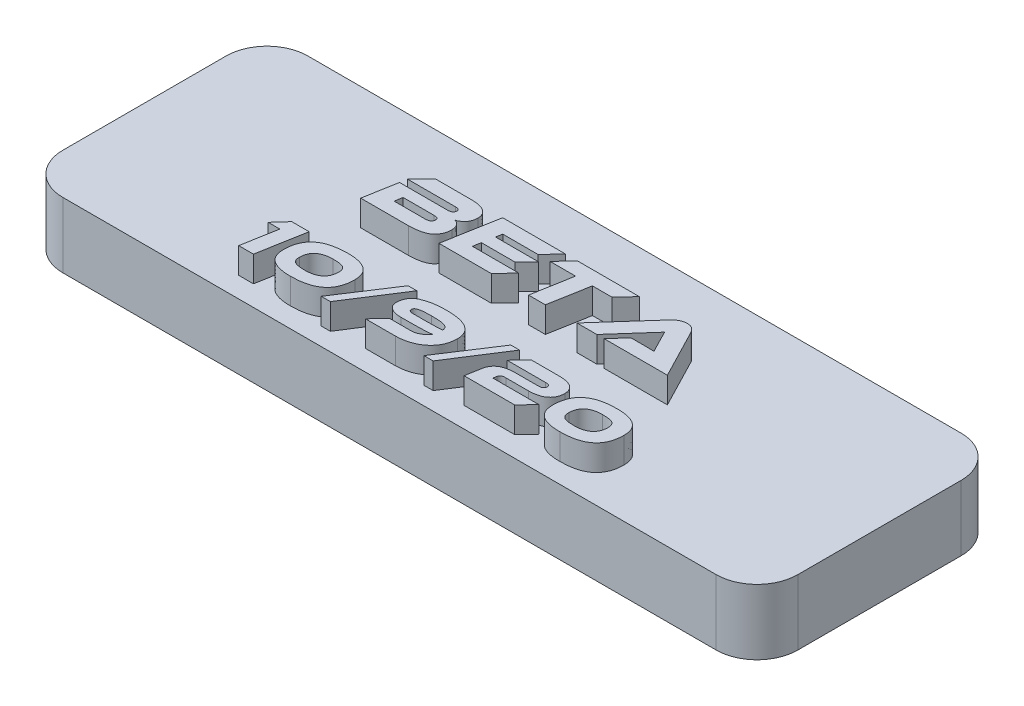
from build123d import *

# Parameters (mm, degrees)
SKETCH1_W           = 57.15
SKETCH1_H           = 19.05
BOSS_EXTRUDE1_DEPTH = 5.08
FILLET1_R           = 3.175
BOSS_EXTRUDE2_DEPTH = 2
SKETCH4_R           = 0.9
CUT_EXTRUDE1_DEPTH  = 4


with BuildPart() as part:
    # Sketch1 → Boss-Extrude1 (new body)
    with BuildSketch(Plane(origin=(0, 0, 0), x_dir=(1, 0, 0), z_dir=(0, 1, 0))):
        Rectangle(SKETCH1_W, SKETCH1_H)
    extrude(amount=BOSS_EXTRUDE1_DEPTH)

    # Fillet1
    fillet1_edges = [part.edges().sort_by_distance(p)[0] for p in [
        (-28.575, 2.54, -9.525),
        (-28.575, 2.54, 9.525),
        (28.575, 2.54, 9.525),
        (28.575, 2.54, -9.525),
    ]]
    fillet(fillet1_edges, radius=FILLET1_R)

    # Sketch3 → Boss-Extrude2 (add)
    with BuildSketch(Plane(origin=(0, 5.08, 0), x_dir=(1, 0, 0), z_dir=(0, 1, 0))):
        with BuildLine():
            Line((12.0752608, 0.006075914), (10.110133747, 3.800574494))
            add(Edge.make_bspline(
                [(10.110133747, 3.800574494), (10.092012803, 3.832806008), (10.056054139, 3.896765269), (9.99118045, 3.985575321), (9.913920963, 4.0630874), (9.829018051, 4.133983071), (9.731212157, 4.192399523), (9.619101008, 4.23493807), (9.49305918, 4.260058315), (9.404328247, 4.264204191), (9.358200531, 4.266359469)],
                knots=[0, 0, 0, 0, 0.000110886, 0.000220038, 0.000328642, 0.000438436, 0.000551159, 0.000668641, 0.000796469, 0.000934872, 0.000934872, 0.000934872, 0.000934872], degree=3))
            add(Edge.make_bspline(
                [(9.358200531, 4.266359469), (9.308388872, 4.264009128), (9.211657751, 4.259444915), (9.071618995, 4.230967468), (8.941340433, 4.187726952), (8.821605558, 4.126959855), (8.711923902, 4.055096369), (8.608722549, 3.977511138), (8.514416335, 3.892229282), (8.457033833, 3.830720556), (8.428505314, 3.800140628)],
                knots=[0, 0, 0, 0, 0.00014941, 0.000290146, 0.000427171, 0.000560039, 0.000691642, 0.000820174, 0.000947034, 0.001072464, 0.001072464, 0.001072464, 0.001072464], degree=3))
            Line((8.428505314, 3.800140628), (5.042507068, 0.006075914))
            Line((5.042507068, 0.006075914), (6.590597512, 0.006075914))
            Line((6.590597512, 0.006075914), (9.067542223, 2.798493231))
            Line((9.067542223, 2.798493231), (9.629909772, 1.696826253))
            add(Edge.make_bspline(
                [(9.629909772, 1.696826253), (9.656583777, 1.644325557), (9.711100024, 1.5370248), (9.780528365, 1.403208105), (9.836611459, 1.297464771), (9.877752573, 1.223921613), (9.914156415, 1.155498073), (9.939454721, 1.112747401), (9.95148686, 1.092414734)],
                knots=[0, 0, 0, 0, 0.000176664, 0.000361065, 0.000452265, 0.000535729, 0.000613867, 0.000684736, 0.000684736, 0.000684736, 0.000684736], degree=3))
            add(Edge.make_bspline(
                [(9.95148686, 1.092414734), (9.896038515, 1.095166522), (9.77787868, 1.101030553), (9.593448145, 1.103502684), (9.398429279, 1.10564963), (9.266176682, 1.105358474), (9.200051787, 1.105212899)],
                knots=[0, 0, 0, 0, 0.000166537, 0.000354888, 0.000553268, 0.00075164, 0.00075164, 0.00075164, 0.00075164], degree=3))
            Line((9.200051787, 1.105212899), (8.145006693, 1.105536066))
            Line((8.145006693, 1.105536066), (7.159283798, 0.006075914))
            Line((7.159283798, 0.006075914), (12.0752608, 0.006075914))
        make_face()
        Polygon((0.896569612, 4.206347541), (-0.152340648, 3.106887389), (1.831742615, 3.106887389), (1.282012539, 0.003655726), (2.589990996, 0.003655726), (3.146039808, 3.106887389), (4.649899097, 3.106887389), (5.698809357, 4.206347541), align=None)
        Polygon((-4.182673258, 1.105536066), (-4.081573474, 1.700326644), (-1.478254033, 1.700326644), (-0.568355976, 2.629107706), (-3.910967588, 2.629107706), (-3.822505277, 3.106887389), (-1.08649237, 3.106887389), (-0.043900846, 4.206347541), (-4.934602903, 4.206347541), (-5.686532547, 0.006075914), (-1.617266236, 0.006075914), (-0.580993449, 1.105536066), align=None)
        with BuildLine():
            add(Edge.make_bspline(
                [(-6.62137524, 2.187185381), (-6.574392147, 2.203247943), (-6.479429873, 2.235713611), (-6.346629309, 2.311746258), (-6.221217039, 2.407162477), (-6.124277095, 2.501677378), (-6.054115517, 2.588230053), (-6.006884659, 2.659861639), (-5.96792723, 2.738536564), (-5.934046167, 2.822101316), (-5.907175532, 2.91174127), (-5.888829435, 3.007382414), (-5.874302744, 3.108635858), (-5.871314591, 3.178462258), (-5.869786618, 3.214167536)],
                knots=[0, 0, 0, 0, 0.00014868, 0.000300512, 0.000456469, 0.000620661, 0.000705179, 0.000790372, 0.000877453, 0.000968101, 0.001060653, 0.001157643, 0.001260037, 0.001367184, 0.001367184, 0.001367184, 0.001367184], degree=3))
            add(Edge.make_bspline(
                [(-5.869786618, 3.214167536), (-5.871317754, 3.253858956), (-5.874292597, 3.330975391), (-5.893774603, 3.443132394), (-5.925851361, 3.547363641), (-5.968980121, 3.644682762), (-6.024442998, 3.734069787), (-6.091490914, 3.816125313), (-6.171525402, 3.889585672), (-6.261864914, 3.956236722), (-6.363340558, 4.014685805), (-6.474468204, 4.065876686), (-6.594977341, 4.109468834), (-6.724857545, 4.145245969), (-6.864222813, 4.172489056), (-7.01330005, 4.191066469), (-7.171650276, 4.203202949), (-7.280303982, 4.205067791), (-7.33609058, 4.206025266)],
                knots=[0, 0, 0, 0, 0.000119065, 0.000231331, 0.000340346, 0.000445509, 0.000549775, 0.000655002, 0.000762375, 0.00087482, 0.000991159, 0.001113043, 0.001241442, 0.001375178, 0.00151681, 0.001667048, 0.001825643, 0.001992996, 0.001992996, 0.001992996, 0.001992996], degree=3))
            Line((-7.33609058, 4.206025266), (-10.134592738, 4.206347541))
            Line((-10.134592738, 4.206347541), (-11.221415418, 3.106887389))
            Line((-11.221415418, 3.106887389), (-7.480723405, 3.106887389))
            add(Edge.make_bspline(
                [(-7.480723405, 3.106887389), (-7.460194509, 3.106630193), (-7.420198205, 3.106129099), (-7.362335635, 3.096227406), (-7.307789509, 3.082436236), (-7.258910264, 3.060323439), (-7.215055925, 3.033212332), (-7.184027367, 2.993605071), (-7.163990004, 2.94620226), (-7.160547969, 2.911487381), (-7.158744589, 2.893299275)],
                knots=[0, 0, 0, 0, 6.1492e-05, 0.000119805, 0.000175688, 0.000229709, 0.000280417, 0.00032853, 0.000378106, 0.000432665, 0.000432665, 0.000432665, 0.000432665], degree=3))
            add(Edge.make_bspline(
                [(-7.158744589, 2.893299275), (-7.160845469, 2.86535707), (-7.164816521, 2.812541115), (-7.189765276, 2.739999455), (-7.230089964, 2.680494349), (-7.286111613, 2.637439539), (-7.350700379, 2.607321442), (-7.420805557, 2.585171427), (-7.496494738, 2.572149557), (-7.54873238, 2.571128072), (-7.575599082, 2.570602705)],
                knots=[0, 0, 0, 0, 8.3794e-05, 0.000158386, 0.00022736, 0.000296317, 0.000367457, 0.000440314, 0.00051636, 0.000596888, 0.000596888, 0.000596888, 0.000596888], degree=3))
            Line((-7.575599082, 2.570602705), (-11.316196465, 2.570602705))
            Line((-11.316196465, 2.570602705), (-11.771145494, 0.006075914))
            Line((-11.771145494, 0.006075914), (-8.055728427, 0.006075914))
            add(Edge.make_bspline(
                [(-8.055728427, 0.006075914), (-8.007813998, 0.007160551), (-7.913832928, 0.009287995), (-7.77565589, 0.016528554), (-7.643406781, 0.027708855), (-7.516806903, 0.041002161), (-7.39646095, 0.05863916), (-7.281968355, 0.078249741), (-7.173837221, 0.102363743), (-7.071639778, 0.128677059), (-6.975293754, 0.15753505), (-6.885555278, 0.190923237), (-6.801211148, 0.225988083), (-6.7235526, 0.265520731), (-6.651572249, 0.307621373), (-6.585885427, 0.353192579), (-6.52608555, 0.401906842), (-6.454971452, 0.469570838), (-6.377484359, 0.559682823), (-6.296411863, 0.672139808), (-6.229413032, 0.789030817), (-6.174871285, 0.909130077), (-6.134412663, 1.033306932), (-6.107787145, 1.161416316), (-6.094726804, 1.293563918), (-6.096509599, 1.382790133), (-6.097411111, 1.427909469)],
                knots=[0, 0, 0, 0, 0.000143776, 0.000282006, 0.000415012, 0.000541908, 0.00066382, 0.000779846, 0.000890304, 0.000996066, 0.00109641, 0.001191851, 0.001283198, 0.001370278, 0.001453058, 0.001533192, 0.001609861, 0.001684223, 0.001827407, 0.001965662, 0.002099572, 0.002230912, 0.002360712, 0.002490516, 0.002622775, 0.002758069, 0.002758069, 0.002758069, 0.002758069], degree=3))
            add(Edge.make_bspline(
                [(-6.097411111, 1.427909469), (-6.099692649, 1.477115185), (-6.104083433, 1.571810809), (-6.132511037, 1.706327142), (-6.178178559, 1.82651134), (-6.241887111, 1.930896451), (-6.320395963, 2.019144873), (-6.410176192, 2.092252982), (-6.510857336, 2.150664811), (-6.584718259, 2.174555082), (-6.62137524, 2.187185381)],
                knots=[0, 0, 0, 0, 0.000147587, 0.000284029, 0.000410503, 0.000531538, 0.000648753, 0.000763114, 0.000877748, 0.000995447, 0.000995447, 0.000995447, 0.000995447], degree=3))
        make_face()
        with BuildLine():
            add(Edge.make_bspline(
                [(-7.758747812, 1.700326644), (-7.72964301, 1.6994496), (-7.675229926, 1.697809917), (-7.599287501, 1.685948139), (-7.534808332, 1.667640036), (-7.481478653, 1.640873892), (-7.440061143, 1.605602768), (-7.410354167, 1.562218177), (-7.394615813, 1.510308523), (-7.393406209, 1.473719839), (-7.392768164, 1.454419952)],
                knots=[0, 0, 0, 0, 8.7282e-05, 0.000163179, 0.000229987, 0.000287637, 0.000340784, 0.000391493, 0.000443246, 0.000501019, 0.000501019, 0.000501019, 0.000501019], degree=3))
            add(Edge.make_bspline(
                [(-7.392768164, 1.454419952), (-7.393315993, 1.427741553), (-7.394362634, 1.376771745), (-7.416286578, 1.305287655), (-7.452431754, 1.243763895), (-7.505459566, 1.194029008), (-7.572544294, 1.153999021), (-7.655874146, 1.128239985), (-7.752723085, 1.109272203), (-7.822612126, 1.106625198), (-7.859901159, 1.105212899)],
                knots=[0, 0, 0, 0, 7.972e-05, 0.000152308, 0.000221603, 0.000291427, 0.00036809, 0.000453948, 0.00055166, 0.000663426, 0.000663426, 0.000663426, 0.000663426], degree=3))
            Line((-7.859901159, 1.105212899), (-10.267286205, 1.105536066))
            Line((-10.267286205, 1.105536066), (-10.166186421, 1.700326644))
            Line((-10.166186421, 1.700326644), (-7.758747812, 1.700326644))
        make_face(mode=Mode.SUBTRACT)
        with BuildLine():
            add(Edge.make_bspline(
                [(12.374340669, -4.205753245), (12.317239313, -4.20639815), (12.204907242, -4.207666832), (12.039195816, -4.213805403), (11.879185029, -4.225246011), (11.724671425, -4.240095428), (11.575776648, -4.260037206), (11.432559303, -4.284920981), (11.294647723, -4.313802188), (11.162098696, -4.346120038), (11.035284787, -4.383749272), (10.91434756, -4.426552533), (10.798324929, -4.472224962), (10.688470655, -4.524117338), (10.583401962, -4.578873484), (10.484385667, -4.638857599), (10.390911032, -4.703243715), (10.303097022, -4.771965987), (10.220238789, -4.844826576), (10.143245148, -4.922821718), (10.071680184, -5.005043307), (10.004270552, -5.090962924), (9.944161792, -5.18251662), (9.887569921, -5.277290921), (9.838403852, -5.377585075), (9.792275881, -5.480915677), (9.753402255, -5.589719203), (9.719021538, -5.702636581), (9.689210536, -5.819692193), (9.666355584, -5.941608197), (9.647756444, -6.06752364), (9.635447597, -6.198094357), (9.626896949, -6.332815699), (9.626182493, -6.424102975), (9.625819287, -6.470510423)],
                knots=[0, 0, 0, 0, 0.000171312, 0.000337012, 0.00049738, 0.000652505, 0.000802621, 0.000947932, 0.001088493, 0.001225264, 0.001357119, 0.001485126, 0.001610044, 0.001730996, 0.001849428, 0.001965345, 0.002078058, 0.002189744, 0.002299681, 0.002408844, 0.002518253, 0.002626572, 0.002736165, 0.002846598, 0.002957491, 0.003071033, 0.00318591, 0.003303822, 0.003425073, 0.003548063, 0.003675777, 0.003806785, 0.003941403, 0.004080604, 0.004080604, 0.004080604, 0.004080604], degree=3))
            add(Edge.make_bspline(
                [(9.625819287, -6.470510423), (9.627176941, -6.532725476), (9.629810681, -6.653417738), (9.655197803, -6.827938058), (9.695721021, -6.990047106), (9.7525154, -7.14024227), (9.82646111, -7.277956037), (9.917021702, -7.403136721), (10.023352013, -7.515956622), (10.146409566, -7.616000774), (10.285895861, -7.702745849), (10.440515685, -7.779438213), (10.611628328, -7.842507446), (10.798186883, -7.895609169), (11.001002293, -7.935791135), (11.219583172, -7.964127031), (11.454092052, -7.98091947), (11.615638791, -7.982880129), (11.699121896, -7.983893345)],
                knots=[0, 0, 0, 0, 0.000186545, 0.000361882, 0.000527754, 0.000687003, 0.000842323, 0.000995285, 0.001149196, 0.001306104, 0.001469661, 0.00164101, 0.001823006, 0.002015943, 0.002222385, 0.002442644, 0.002676813, 0.00292724, 0.00292724, 0.00292724, 0.00292724], degree=3))
            add(Edge.make_bspline(
                [(11.699121896, -7.983893345), (11.75591946, -7.983380019), (11.867417529, -7.98237232), (12.032008362, -7.975990544), (12.191023017, -7.965003258), (12.344878401, -7.948680913), (12.493330341, -7.929266178), (12.635969307, -7.904105738), (12.773236057, -7.875596387), (12.904737671, -7.841995411), (13.031086924, -7.804464931), (13.151623906, -7.761989808), (13.267162184, -7.715814846), (13.37695752, -7.664606669), (13.48093553, -7.608490903), (13.579854168, -7.548339608), (13.673226984, -7.483895632), (13.760936312, -7.414499954), (13.843341161, -7.341424669), (13.919342052, -7.262809113), (13.991930735, -7.18190029), (14.057459891, -7.094705032), (14.118138242, -7.003516426), (14.174549308, -6.908219643), (14.224711509, -6.808134503), (14.269649232, -6.703993625), (14.308740694, -6.595424725), (14.343410979, -6.482622195), (14.371732995, -6.364960314), (14.395969103, -6.243348255), (14.414375056, -6.117331748), (14.426750069, -5.986773695), (14.43522599, -5.851777937), (14.435958151, -5.760225753), (14.436329275, -5.713818961)],
                knots=[0, 0, 0, 0, 0.000170392, 0.000334494, 0.000494064, 0.000648473, 0.00079859, 0.000943113, 0.001082891, 0.001219081, 0.001350169, 0.001478176, 0.001602352, 0.001723304, 0.001841405, 0.001956639, 0.002070464, 0.002181522, 0.00229199, 0.002400592, 0.0025094, 0.002617866, 0.002727459, 0.002837893, 0.002949859, 0.003063082, 0.00317796, 0.003295871, 0.003416929, 0.003540857, 0.00366778, 0.003798788, 0.003934205, 0.004073405, 0.004073405, 0.004073405, 0.004073405], degree=3))
            add(Edge.make_bspline(
                [(14.436329275, -5.713818961), (14.43498762, -5.651864372), (14.432379489, -5.53142685), (14.406666925, -5.357329546), (14.367479439, -5.194951682), (14.310453972, -5.045253766), (14.237085855, -4.907894424), (14.147830754, -4.782830639), (14.041725948, -4.670804764), (13.920105144, -4.570938519), (13.781557034, -4.484275151), (13.627367339, -4.409545186), (13.457489134, -4.345204255), (13.271561733, -4.293863202), (13.069630563, -4.25419887), (12.852168928, -4.225768444), (12.618455287, -4.209016704), (12.457441416, -4.207051109), (12.374340669, -4.205753245)],
                knots=[0, 0, 0, 0, 0.000185746, 0.000361083, 0.00052676, 0.000686009, 0.000840246, 0.000992741, 0.001145521, 0.00130181, 0.001463587, 0.001634583, 0.001815083, 0.002007802, 0.002212518, 0.002431984, 0.002665356, 0.002914983, 0.002914983, 0.002914983, 0.002914983], degree=3))
        make_face()
        with BuildLine():
            add(Edge.make_bspline(
                [(11.86568238, -7.021348599), (11.8194893, -7.021854174), (11.730334765, -7.022829956), (11.60141977, -7.017591194), (11.482074307, -7.009340097), (11.372313208, -6.995853431), (11.272049166, -6.977791428), (11.181505833, -6.954558851), (11.100166608, -6.92776808), (11.027958792, -6.89577873), (10.96396743, -6.85746675), (10.909940859, -6.809228041), (10.863371147, -6.753532905), (10.826820836, -6.688452997), (10.797685771, -6.615916979), (10.778224967, -6.534816355), (10.765912812, -6.445830998), (10.765217218, -6.383634321), (10.764855906, -6.351327518)],
                knots=[0, 0, 0, 0, 0.000138565, 0.000267436, 0.000386943, 0.000497368, 0.000599032, 0.000692348, 0.000777591, 0.00085564, 0.000928899, 0.001000308, 0.001071897, 0.001145712, 0.001223247, 0.001305698, 0.001395292, 0.001492131, 0.001492131, 0.001492131, 0.001492131], degree=3))
            add(Edge.make_bspline(
                [(10.764855906, -6.351327518), (10.766392759, -6.304070169), (10.769382846, -6.212126705), (10.788044786, -6.079013736), (10.817300229, -5.954439253), (10.859118048, -5.839274516), (10.911175676, -5.731825667), (10.976385898, -5.634468641), (11.052201768, -5.545120744), (11.140147315, -5.466071948), (11.238120391, -5.395226287), (11.346722869, -5.334487382), (11.465103405, -5.283435533), (11.592697011, -5.240941797), (11.730029982, -5.208296683), (11.876899843, -5.185693562), (12.033434061, -5.170762309), (12.141155378, -5.169135367), (12.196650531, -5.16829721)],
                knots=[0, 0, 0, 0, 0.000141763, 0.000275812, 0.0004025, 0.000524963, 0.000642655, 0.000759791, 0.000875529, 0.00099331, 0.001113634, 0.001237554, 0.001365798, 0.001499859, 0.001640517, 0.001788722, 0.001945363, 0.002111808, 0.002111808, 0.002111808, 0.002111808], degree=3))
            add(Edge.make_bspline(
                [(12.196650531, -5.16829721), (12.242779181, -5.168009724), (12.3318575, -5.167454564), (12.461007813, -5.171313587), (12.580618945, -5.17974049), (12.690556031, -5.193477036), (12.790849239, -5.210588071), (12.881560995, -5.232796313), (12.962755297, -5.25982086), (13.035040085, -5.291687778), (13.098665678, -5.330152418), (13.153061044, -5.377160874), (13.19864834, -5.432670471), (13.235572883, -5.496790682), (13.264422198, -5.569240936), (13.283849223, -5.650050065), (13.29628475, -5.738759012), (13.296947129, -5.80069376), (13.297292657, -5.833001866)],
                knots=[0, 0, 0, 0, 0.00013838, 0.000267224, 0.000387529, 0.000497953, 0.000599476, 0.000692596, 0.00077784, 0.000855889, 0.000929147, 0.001000031, 0.001070493, 0.001143616, 0.001221151, 0.001303602, 0.001392403, 0.001489242, 0.001489242, 0.001489242, 0.001489242], degree=3))
            add(Edge.make_bspline(
                [(13.297292657, -5.833001866), (13.295755137, -5.880258006), (13.292763753, -5.972199119), (13.274074918, -6.105585977), (13.244713969, -6.230260661), (13.204011304, -6.346409008), (13.151009147, -6.453739693), (13.085591885, -6.551573704), (13.009947875, -6.64153852), (12.922305875, -6.721564153), (12.823890928, -6.791879743), (12.716346043, -6.854243117), (12.597796705, -6.904835069), (12.470156572, -6.947243215), (12.332961399, -6.980841995), (12.185859835, -7.004512108), (12.028969086, -7.019068958), (11.920989456, -7.020761541), (11.86568238, -7.021348599)],
                knots=[0, 0, 0, 0, 0.000141763, 0.000275812, 0.000403278, 0.000525472, 0.000644235, 0.000761371, 0.000877718, 0.000996039, 0.001116363, 0.001239983, 0.001368227, 0.001502288, 0.001643134, 0.001791467, 0.001948904, 0.002115349, 0.002115349, 0.002115349, 0.002115349], degree=3))
        make_face(mode=Mode.SUBTRACT)
        with BuildLine():
            Line((4.843044384, -5.218973535), (7.834176278, -5.218973535))
            add(Edge.make_bspline(
                [(7.834176278, -5.218973535), (7.861877192, -5.218922741), (7.913723567, -5.218827674), (7.98645257, -5.225918073), (8.047976611, -5.242216387), (8.099807148, -5.26353583), (8.139900537, -5.294908436), (8.168214537, -5.334273792), (8.185766514, -5.381008794), (8.186991214, -5.4147712), (8.18762558, -5.432259348)],
                knots=[0, 0, 0, 0, 8.3099e-05, 0.000155531, 0.000218392, 0.000273538, 0.000322508, 0.000368908, 0.000417497, 0.000469711, 0.000469711, 0.000469711, 0.000469711], degree=3))
            add(Edge.make_bspline(
                [(8.18762558, -5.432259348), (8.186985786, -5.458018948), (8.185776182, -5.506720508), (8.165213796, -5.573936821), (8.13192742, -5.630194031), (8.082713797, -5.673414306), (8.019182698, -5.704561408), (7.941448531, -5.726311626), (7.848323372, -5.738498194), (7.781321727, -5.73961472), (7.745289028, -5.740215175)],
                knots=[0, 0, 0, 0, 7.6993e-05, 0.000145564, 0.000208395, 0.000270703, 0.000339032, 0.00041902, 0.000511893, 0.000619952, 0.000619952, 0.000619952, 0.000619952], degree=3))
            Line((7.745289028, -5.740215175), (5.987525534, -5.739416071))
            add(Edge.make_bspline(
                [(5.987525534, -5.739416071), (5.931923378, -5.740560639), (5.823670216, -5.742789025), (5.665674889, -5.753609346), (5.51695553, -5.772857955), (5.377332662, -5.798779792), (5.247069464, -5.833149331), (5.125990611, -5.875619954), (5.013723231, -5.92500466), (4.910521364, -5.98174212), (4.817052167, -6.047028209), (4.732526674, -6.120143527), (4.657126065, -6.201107035), (4.591125043, -6.289606037), (4.534743469, -6.385733808), (4.487647714, -6.489539314), (4.448700351, -6.600822081), (4.431378675, -6.678800473), (4.422565634, -6.718474855)],
                knots=[0, 0, 0, 0, 0.000166829, 0.000324804, 0.000474816, 0.000616477, 0.000750546, 0.000878553, 0.001001026, 0.001118108, 0.001231277, 0.001342418, 0.001452782, 0.001562526, 0.00167296, 0.001786425, 0.001904052, 0.002025887, 0.002025887, 0.002025887, 0.002025887], degree=3))
            Line((4.422565634, -6.718474855), (4.207221523, -7.932183575))
            Line((4.207221523, -7.932183575), (8.143794367, -7.932183575))
            Line((8.143794367, -7.932183575), (9.050533056, -6.970155942))
            Line((9.050533056, -6.970155942), (5.478867245, -6.970155942))
            Line((5.478867245, -6.970155942), (5.528627295, -6.707239748))
            add(Edge.make_bspline(
                [(5.528627295, -6.707239748), (5.532404819, -6.686112106), (5.539727576, -6.645156023), (5.568438929, -6.590591717), (5.606799622, -6.543848716), (5.658138953, -6.508043577), (5.71921442, -6.47963759), (5.79153204, -6.461031101), (5.874595461, -6.450993538), (5.933518971, -6.450679637), (5.964744426, -6.450513291)],
                knots=[0, 0, 0, 0, 6.4036e-05, 0.000124134, 0.000182613, 0.000243892, 0.000310094, 0.000383827, 0.000466868, 0.000560486, 0.000560486, 0.000560486, 0.000560486], degree=3))
            Line((5.964744426, -6.450513291), (7.723598389, -6.449714187))
            add(Edge.make_bspline(
                [(7.723598389, -6.449714187), (7.789279414, -6.448593152), (7.916613855, -6.446419826), (8.100511704, -6.426694059), (8.271928314, -6.400940141), (8.4297752, -6.361961645), (8.575529194, -6.315052912), (8.706870449, -6.255202462), (8.826343564, -6.187512089), (8.931056004, -6.107690588), (9.023639196, -6.020066732), (9.104095557, -5.925525662), (9.171874442, -5.823724541), (9.227627244, -5.715194429), (9.269763213, -5.599220599), (9.300458649, -5.476792913), (9.318113994, -5.347458364), (9.320066948, -5.259004345), (9.321063001, -5.21389067)],
                knots=[0, 0, 0, 0, 0.00019697, 0.000381861, 0.000554393, 0.000716581, 0.000869107, 0.001013024, 0.00114885, 0.001280192, 0.001406932, 0.001530654, 0.001651783, 0.001773055, 0.001895792, 0.002021116, 0.002151095, 0.002286391, 0.002286391, 0.002286391, 0.002286391], degree=3))
            add(Edge.make_bspline(
                [(9.321063001, -5.21389067), (9.320610546, -5.1780961), (9.319724802, -5.108023129), (9.303514954, -5.005989197), (9.279522882, -4.909275966), (9.242988179, -4.818686266), (9.195353826, -4.734234215), (9.137274784, -4.655338408), (9.068907157, -4.582231577), (8.989612717, -4.515185386), (8.8987898, -4.455053695), (8.79521118, -4.402688892), (8.678978059, -4.359688685), (8.55079058, -4.322394884), (8.409987571, -4.294289614), (8.256640525, -4.27367202), (8.090773995, -4.26108405), (7.975944379, -4.258543735), (7.916464475, -4.257227893)],
                knots=[0, 0, 0, 0, 0.000107259, 0.000209975, 0.000309113, 0.00040566, 0.000501999, 0.00059927, 0.000698874, 0.0008016, 0.000910084, 0.001024914, 0.001148961, 0.001281358, 0.001425053, 0.00157924, 0.00174531, 0.001923772, 0.001923772, 0.001923772, 0.001923772], degree=3))
            Line((7.916464475, -4.257227893), (5.749783073, -4.256945902))
            Line((5.749783073, -4.256945902), (4.843044384, -5.218973535))
        make_face()
        Polygon((3.957233943, -4.05005839), (1.292306821, -8.139071868), (2.005534204, -8.139071868), (4.631759065, -4.05005839), align=None)
        with BuildLine():
            Line((-2.557665164, -6.970155942), (-3.452921125, -7.932183575))
            Line((-3.452921125, -7.932183575), (-1.134743484, -7.932183575))
            add(Edge.make_bspline(
                [(-1.134743484, -7.932183575), (-1.044897228, -7.929777147), (-0.868327525, -7.92504793), (-0.609316661, -7.89377972), (-0.36127733, -7.845456505), (-0.124789016, -7.778119368), (0.100483785, -7.693257531), (0.314160255, -7.589683886), (0.516243704, -7.467776465), (0.674424764, -7.351552012), (0.793660056, -7.251102183), (0.877009845, -7.171271707), (0.955534864, -7.089073015), (1.028750052, -7.003301544), (1.095489507, -6.913691428), (1.157823493, -6.821436558), (1.213384965, -6.725101624), (1.265039621, -6.626227548), (1.309699037, -6.523415525), (1.348869977, -6.417304195), (1.383510073, -6.308297587), (1.411113964, -6.195383605), (1.434865164, -6.079711014), (1.450910869, -5.960192069), (1.463548774, -5.837767761), (1.466896702, -5.75491021), (1.468589348, -5.713019076)],
                knots=[0, 0, 0, 0, 0.000269512, 0.000529657, 0.000781592, 0.001026938, 0.001266417, 0.001502887, 0.001738287, 0.001973466, 0.00209094, 0.002205793, 0.002319514, 0.002431869, 0.002543853, 0.002654555, 0.002765679, 0.002877297, 0.002989052, 0.003101677, 0.003216532, 0.003331962, 0.003450243, 0.003570604, 0.003693573, 0.003819318, 0.003819318, 0.003819318, 0.003819318], degree=3))
            add(Edge.make_bspline(
                [(1.468589348, -5.713019076), (1.466464228, -5.652117472), (1.462330437, -5.533651456), (1.433941811, -5.361744864), (1.387653029, -5.20161806), (1.323431746, -5.05300733), (1.240814082, -4.916595218), (1.141285742, -4.79126316), (1.021584981, -4.67984859), (0.886130694, -4.578328397), (0.73142821, -4.490460709), (0.55969407, -4.413762538), (0.370014239, -4.349318484), (0.162950263, -4.296844754), (-0.061910703, -4.256528236), (-0.304420412, -4.227593809), (-0.564681799, -4.208531898), (-0.744124273, -4.206884801), (-0.836679988, -4.206035236)],
                knots=[0, 0, 0, 0, 0.00018267, 0.00035533, 0.000521131, 0.000681619, 0.000839513, 0.000998287, 0.001160113, 0.00132873, 0.001505033, 0.001692644, 0.001892226, 0.002105242, 0.002332894, 0.00257706, 0.002837673, 0.00311529, 0.00311529, 0.00311529, 0.00311529], degree=3))
            add(Edge.make_bspline(
                [(-0.836679988, -4.206035236), (-0.919878842, -4.205592276), (-1.083417671, -4.204721577), (-1.324656293, -4.215578286), (-1.557477121, -4.234927868), (-1.781903272, -4.265660573), (-1.998050571, -4.305110003), (-2.205472113, -4.355643498), (-2.404392321, -4.415783415), (-2.563836838, -4.473503284), (-2.685697056, -4.525130752), (-2.770163401, -4.569635858), (-2.850171078, -4.616422557), (-2.923378106, -4.668834502), (-2.992257643, -4.723868288), (-3.054465933, -4.784450305), (-3.112433697, -4.847987079), (-3.163798753, -4.916899938), (-3.210180339, -4.989145242), (-3.250361198, -5.066161285), (-3.285603592, -5.146801308), (-3.315168699, -5.2318633), (-3.339172718, -5.32088445), (-3.357438248, -5.41389817), (-3.37046186, -5.510872203), (-3.3743422, -5.57700115), (-3.376315707, -5.610633762)],
                knots=[0, 0, 0, 0, 0.000249565, 0.000490555, 0.000724179, 0.0009502, 0.001169841, 0.001383052, 0.001590297, 0.00179299, 0.001891509, 0.001987031, 0.002079216, 0.002169319, 0.002256891, 0.002343445, 0.002429536, 0.002514644, 0.002600961, 0.002686833, 0.002774954, 0.002864759, 0.002956732, 0.003051325, 0.003148954, 0.003249996, 0.003249996, 0.003249996, 0.003249996], degree=3))
            add(Edge.make_bspline(
                [(-3.376315707, -5.610633762), (-3.374880852, -5.643753438), (-3.372075356, -5.708510641), (-3.356193962, -5.802650158), (-3.329206547, -5.890402518), (-3.294403331, -5.972873051), (-3.248285948, -6.048807605), (-3.191721599, -6.117637999), (-3.126110505, -6.18094304), (-3.050646005, -6.237416652), (-2.966679944, -6.287658407), (-2.874653991, -6.330947125), (-2.775047598, -6.367615523), (-2.667608804, -6.398128227), (-2.552233717, -6.420818141), (-2.429374898, -6.437537883), (-2.29904804, -6.448004733), (-2.209569457, -6.449663014), (-2.163689644, -6.450513291)],
                knots=[0, 0, 0, 0, 9.9392e-05, 0.000194336, 0.000285432, 0.000374287, 0.00046222, 0.000550917, 0.000640864, 0.000735091, 0.000833037, 0.000933937, 0.001039728, 0.001151139, 0.001268635, 0.001392165, 0.00152296, 0.001660599, 0.001660599, 0.001660599, 0.001660599], degree=3))
            add(Edge.make_bspline(
                [(-2.163689644, -6.450513291), (-2.110097138, -6.450588766), (-2.005311096, -6.450736339), (-1.851734394, -6.449683936), (-1.704822078, -6.448934551), (-1.564841867, -6.448155746), (-1.431528578, -6.447263447), (-1.305140899, -6.446777451), (-1.185429975, -6.444902162), (-1.07237807, -6.443402764), (-0.966262797, -6.441665317), (-0.867061298, -6.440519694), (-0.774568218, -6.437415789), (-0.6889522, -6.436504009), (-0.610042771, -6.433778787), (-0.538056481, -6.43134803), (-0.472699753, -6.429349577), (-0.395959363, -6.424605461), (-0.308700962, -6.420771207), (-0.211432537, -6.413793257), (-0.122833184, -6.408049685), (-0.042959266, -6.400065169), (0.028426402, -6.394706302), (0.090717672, -6.386176476), (0.1443788, -6.378534723), (0.177056765, -6.372485855), (0.191972464, -6.369724879)],
                knots=[0, 0, 0, 0, 0.000160777, 0.000314357, 0.000460738, 0.00060152, 0.000734304, 0.000860688, 0.000980681, 0.001093477, 0.001199873, 0.001299072, 0.00139109, 0.001477493, 0.001555918, 0.001627948, 0.001693582, 0.001752061, 0.001858593, 0.001955591, 0.002044608, 0.00212492, 0.002196397, 0.002259299, 0.002313485, 0.002358987, 0.002358987, 0.002358987, 0.002358987], degree=3))
            add(Edge.make_bspline(
                [(0.191972464, -6.369724879), (0.162251408, -6.410755391), (0.102406135, -6.493372984), (-0.005287966, -6.604032197), (-0.12521206, -6.70577684), (-0.235755023, -6.780745718), (-0.330711064, -6.833676621), (-0.405510818, -6.868964979), (-0.482751272, -6.899761591), (-0.563643191, -6.923136897), (-0.646719372, -6.943784293), (-0.733436784, -6.957621584), (-0.822853723, -6.967749518), (-0.883577836, -6.969535864), (-0.914268859, -6.970438714)],
                knots=[0, 0, 0, 0, 0.000151822, 0.000305704, 0.000461788, 0.000623076, 0.000705429, 0.000787724, 0.000871054, 0.000954565, 0.001040123, 0.001127702, 0.001217802, 0.001309875, 0.001309875, 0.001309875, 0.001309875], degree=3))
            Line((-0.914268859, -6.970438714), (-2.557665164, -6.970155942))
        make_face()
        with BuildLine():
            add(Edge.make_bspline(
                [(-1.947490967, -5.739416071), (-1.975875986, -5.739333167), (-2.0290647, -5.739177819), (-2.102815029, -5.728388524), (-2.165702433, -5.712937853), (-2.217625578, -5.691097621), (-2.258744812, -5.66209877), (-2.286959552, -5.625127048), (-2.305091841, -5.582069955), (-2.306262538, -5.550830586), (-2.306869106, -5.534644662)],
                knots=[0, 0, 0, 0, 8.5051e-05, 0.000159372, 0.000223007, 0.000278884, 0.00032752, 0.000371998, 0.000416856, 0.000465088, 0.000465088, 0.000465088, 0.000465088], degree=3))
            add(Edge.make_bspline(
                [(-2.306869106, -5.534644662), (-2.308071392, -5.520492659), (-2.310425318, -5.492784798), (-2.302478644, -5.451904192), (-2.287198755, -5.413284736), (-2.262284421, -5.377865243), (-2.229997418, -5.344746874), (-2.188732514, -5.315137149), (-2.140104097, -5.287204256), (-2.081620395, -5.262102266), (-2.011125451, -5.239181686), (-1.924986563, -5.220969825), (-1.823044429, -5.204302076), (-1.704772838, -5.19102051), (-1.570305014, -5.180808804), (-1.419313849, -5.174134861), (-1.252121235, -5.169033665), (-1.135308398, -5.168550026), (-1.074245912, -5.16829721)],
                knots=[0, 0, 0, 0, 4.2424e-05, 8.3061e-05, 0.000123611, 0.000166209, 0.000212026, 0.00026178, 0.000318034, 0.000380003, 0.000452348, 0.000540062, 0.000643816, 0.000762183, 0.000896965, 0.001048315, 0.00121556, 0.00139874, 0.00139874, 0.00139874, 0.00139874], degree=3))
            add(Edge.make_bspline(
                [(-1.074245912, -5.16829721), (-1.021719383, -5.167787601), (-0.919593467, -5.166796781), (-0.77104867, -5.169363834), (-0.631768573, -5.174373781), (-0.501942193, -5.184530804), (-0.381245923, -5.195834798), (-0.269863294, -5.211544935), (-0.168123775, -5.232098586), (-0.074910827, -5.253456427), (0.008709933, -5.280784321), (0.082199887, -5.316195779), (0.144842199, -5.359607715), (0.198410433, -5.409671023), (0.24015145, -5.468468051), (0.273006103, -5.534032814), (0.293452939, -5.607713922), (0.299334903, -5.659314386), (0.30235663, -5.685822977)],
                knots=[0, 0, 0, 0, 0.000157579, 0.000306377, 0.00044567, 0.000575606, 0.000696984, 0.000809313, 0.000912848, 0.001008299, 0.001096072, 0.001176204, 0.001252088, 0.00132394, 0.001394981, 0.001467241, 0.001542944, 0.00162292, 0.00162292, 0.00162292, 0.00162292], degree=3))
            add(Edge.make_bspline(
                [(0.30235663, -5.685822977), (0.284765926, -5.688016622), (0.247218461, -5.692698971), (0.187461376, -5.698817251), (0.120886582, -5.705774202), (0.047459513, -5.709867374), (-0.032516243, -5.714809123), (-0.119152794, -5.719762177), (-0.212483555, -5.723691176), (-0.31568316, -5.726773296), (-0.434853019, -5.730355113), (-0.576450031, -5.73231403), (-0.743357416, -5.734779827), (-0.93532691, -5.737306699), (-1.152632385, -5.738848781), (-1.395266673, -5.739352636), (-1.663227301, -5.740463735), (-1.850134484, -5.740300435), (-1.947490967, -5.739416071)],
                knots=[0, 0, 0, 0, 5.3179e-05, 0.000113511, 0.000180209, 0.000253954, 0.000334087, 0.000420608, 0.00051428, 0.000614317, 0.000730344, 0.000871944, 0.001039137, 0.001231125, 0.0014479, 0.001691066, 0.001959029, 0.002251787, 0.002251787, 0.002251787, 0.002251787], degree=3))
        make_face(mode=Mode.SUBTRACT)
        Polygon((-4.02882055, -4.05005839), (-6.693747672, -8.139071868), (-5.980520288, -8.139071868), (-3.354295428, -4.05005839), align=None)
        with BuildLine():
            add(Edge.make_bspline(
                [(-8.563456046, -4.205753245), (-8.620557402, -4.20639815), (-8.732889473, -4.207666832), (-8.898600899, -4.213805403), (-9.058611686, -4.225246011), (-9.21312529, -4.240095428), (-9.362020067, -4.260037206), (-9.505237412, -4.284920981), (-9.643148992, -4.313802188), (-9.775698019, -4.346120038), (-9.902511928, -4.383749272), (-10.023449155, -4.426552533), (-10.139471786, -4.472224962), (-10.24932606, -4.524117338), (-10.354394753, -4.578873484), (-10.453411048, -4.638857599), (-10.546885683, -4.703243715), (-10.634699693, -4.771965987), (-10.717557926, -4.844826576), (-10.794551567, -4.922821718), (-10.866116531, -5.005043307), (-10.933526163, -5.090962924), (-10.993634923, -5.18251662), (-11.050226794, -5.277290921), (-11.099392862, -5.377585075), (-11.145520834, -5.480915677), (-11.184394459, -5.589719203), (-11.218775177, -5.702636581), (-11.248586179, -5.819692193), (-11.271441131, -5.941608197), (-11.29004027, -6.06752364), (-11.302349118, -6.198094357), (-11.310899766, -6.332815699), (-11.311614222, -6.424102975), (-11.311977428, -6.470510423)],
                knots=[0, 0, 0, 0, 0.000171312, 0.000337012, 0.00049738, 0.000652505, 0.000802621, 0.000947932, 0.001088493, 0.001225264, 0.001357119, 0.001485126, 0.001610044, 0.001730996, 0.001849428, 0.001965345, 0.002078058, 0.002189744, 0.002299681, 0.002408844, 0.002518253, 0.002626572, 0.002736165, 0.002846598, 0.002957491, 0.003071033, 0.00318591, 0.003303822, 0.003425073, 0.003548063, 0.003675777, 0.003806785, 0.003941403, 0.004080604, 0.004080604, 0.004080604, 0.004080604], degree=3))
            add(Edge.make_bspline(
                [(-11.311977428, -6.470510423), (-11.310619774, -6.532725476), (-11.307986034, -6.653417738), (-11.282598912, -6.827938058), (-11.242075694, -6.990047106), (-11.185281315, -7.14024227), (-11.111335605, -7.277956037), (-11.020775013, -7.403136721), (-10.914444702, -7.515956622), (-10.791387149, -7.616000774), (-10.651900854, -7.702745849), (-10.49728103, -7.779438213), (-10.326168387, -7.842507446), (-10.139609832, -7.895609169), (-9.936794422, -7.935791135), (-9.718213543, -7.964127031), (-9.483704663, -7.98091947), (-9.322157924, -7.982880129), (-9.238674819, -7.983893345)],
                knots=[0, 0, 0, 0, 0.000186545, 0.000361882, 0.000527754, 0.000687003, 0.000842323, 0.000995285, 0.001149196, 0.001306104, 0.001469661, 0.00164101, 0.001823006, 0.002015943, 0.002222385, 0.002442644, 0.002676813, 0.00292724, 0.00292724, 0.00292724, 0.00292724], degree=3))
            add(Edge.make_bspline(
                [(-9.238674819, -7.983893345), (-9.181877255, -7.983380019), (-9.070379186, -7.98237232), (-8.905788353, -7.975990544), (-8.746773698, -7.965003258), (-8.592918314, -7.948680913), (-8.444466374, -7.929266178), (-8.301827408, -7.904105738), (-8.164560658, -7.875596387), (-8.033059044, -7.841995411), (-7.906709791, -7.804464931), (-7.786172809, -7.761989808), (-7.670634531, -7.715814846), (-7.560839195, -7.664606669), (-7.456861185, -7.608490903), (-7.357942547, -7.548339608), (-7.264569731, -7.483895632), (-7.176860403, -7.414499954), (-7.094455554, -7.341424669), (-7.018454663, -7.262809113), (-6.94586598, -7.18190029), (-6.880336824, -7.094705032), (-6.819658473, -7.003516426), (-6.763247407, -6.908219643), (-6.713085206, -6.808134503), (-6.668147483, -6.703993625), (-6.629056021, -6.595424725), (-6.594385736, -6.482622195), (-6.56606372, -6.364960314), (-6.541827612, -6.243348255), (-6.523421659, -6.117331748), (-6.511046646, -5.986773695), (-6.502570725, -5.851777937), (-6.501838564, -5.760225753), (-6.50146744, -5.713818961)],
                knots=[0, 0, 0, 0, 0.000170392, 0.000334494, 0.000494064, 0.000648473, 0.00079859, 0.000943113, 0.001082891, 0.001219081, 0.001350169, 0.001478176, 0.001602352, 0.001723304, 0.001841405, 0.001956639, 0.002070464, 0.002181522, 0.00229199, 0.002400592, 0.0025094, 0.002617866, 0.002727459, 0.002837893, 0.002949859, 0.003063082, 0.00317796, 0.003295871, 0.003416929, 0.003540857, 0.00366778, 0.003798788, 0.003934205, 0.004073405, 0.004073405, 0.004073405, 0.004073405], degree=3))
            add(Edge.make_bspline(
                [(-6.50146744, -5.713818961), (-6.502809095, -5.651864372), (-6.505417226, -5.53142685), (-6.53112979, -5.357329546), (-6.570317276, -5.194951682), (-6.627342743, -5.045253766), (-6.70071086, -4.907894424), (-6.789965961, -4.782830639), (-6.896070767, -4.670804764), (-7.017691571, -4.570938519), (-7.156239681, -4.484275151), (-7.310429376, -4.409545186), (-7.480307581, -4.345204255), (-7.666234982, -4.293863202), (-7.868166152, -4.25419887), (-8.085627787, -4.225768444), (-8.319341428, -4.209016704), (-8.480355299, -4.207051109), (-8.563456046, -4.205753245)],
                knots=[0, 0, 0, 0, 0.000185746, 0.000361083, 0.00052676, 0.000686009, 0.000840246, 0.000992741, 0.001145521, 0.00130181, 0.001463587, 0.001634583, 0.001815083, 0.002007802, 0.002212518, 0.002431984, 0.002665356, 0.002914983, 0.002914983, 0.002914983, 0.002914983], degree=3))
        make_face()
        with BuildLine():
            add(Edge.make_bspline(
                [(-9.072114335, -7.021348599), (-9.118307415, -7.021854174), (-9.20746195, -7.022829956), (-9.336376945, -7.017591194), (-9.455722408, -7.009340097), (-9.565483507, -6.995853431), (-9.665747549, -6.977791428), (-9.756290882, -6.954558851), (-9.837630107, -6.92776808), (-9.909837923, -6.89577873), (-9.973829285, -6.85746675), (-10.027855856, -6.809228041), (-10.074425568, -6.753532905), (-10.110975879, -6.688452997), (-10.140110944, -6.615916979), (-10.159571748, -6.534816355), (-10.171883903, -6.445830998), (-10.172579497, -6.383634321), (-10.172940809, -6.351327518)],
                knots=[0, 0, 0, 0, 0.000138565, 0.000267436, 0.000386943, 0.000497368, 0.000599032, 0.000692348, 0.000777591, 0.00085564, 0.000928899, 0.001000308, 0.001071897, 0.001145712, 0.001223247, 0.001305698, 0.001395292, 0.001492131, 0.001492131, 0.001492131, 0.001492131], degree=3))
            add(Edge.make_bspline(
                [(-10.172940809, -6.351327518), (-10.171403956, -6.304070169), (-10.168413869, -6.212126705), (-10.149751929, -6.079013736), (-10.120496486, -5.954439253), (-10.078678667, -5.839274516), (-10.026621039, -5.731825667), (-9.961410817, -5.634468641), (-9.885594947, -5.545120744), (-9.7976494, -5.466071948), (-9.699676324, -5.395226287), (-9.591073846, -5.334487382), (-9.47269331, -5.283435533), (-9.345099704, -5.240941797), (-9.207766733, -5.208296683), (-9.060896872, -5.185693562), (-8.904362654, -5.170762309), (-8.796641337, -5.169135367), (-8.741146184, -5.16829721)],
                knots=[0, 0, 0, 0, 0.000141763, 0.000275812, 0.0004025, 0.000524963, 0.000642655, 0.000759791, 0.000875529, 0.00099331, 0.001113634, 0.001237554, 0.001365798, 0.001499859, 0.001640517, 0.001788722, 0.001945363, 0.002111808, 0.002111808, 0.002111808, 0.002111808], degree=3))
            add(Edge.make_bspline(
                [(-8.741146184, -5.16829721), (-8.695017534, -5.168009724), (-8.605939215, -5.167454564), (-8.476788902, -5.171313587), (-8.35717777, -5.17974049), (-8.247240684, -5.193477036), (-8.146947476, -5.210588071), (-8.05623572, -5.232796313), (-7.975041418, -5.25982086), (-7.90275663, -5.291687778), (-7.839131037, -5.330152418), (-7.784735671, -5.377160874), (-7.739148375, -5.432670471), (-7.702223832, -5.496790682), (-7.673374517, -5.569240936), (-7.653947492, -5.650050065), (-7.641511965, -5.738759012), (-7.640849586, -5.80069376), (-7.640504058, -5.833001866)],
                knots=[0, 0, 0, 0, 0.00013838, 0.000267224, 0.000387529, 0.000497953, 0.000599476, 0.000692596, 0.00077784, 0.000855889, 0.000929147, 0.001000031, 0.001070493, 0.001143616, 0.001221151, 0.001303602, 0.001392403, 0.001489242, 0.001489242, 0.001489242, 0.001489242], degree=3))
            add(Edge.make_bspline(
                [(-7.640504058, -5.833001866), (-7.642041578, -5.880258006), (-7.645032962, -5.972199119), (-7.663721797, -6.105585977), (-7.693082746, -6.230260661), (-7.733785411, -6.346409008), (-7.786787568, -6.453739693), (-7.85220483, -6.551573704), (-7.92784884, -6.64153852), (-8.01549084, -6.721564153), (-8.113905787, -6.791879743), (-8.221450672, -6.854243117), (-8.34000001, -6.904835069), (-8.467640143, -6.947243215), (-8.604835316, -6.980841995), (-8.75193688, -7.004512108), (-8.908827629, -7.019068958), (-9.016807259, -7.020761541), (-9.072114335, -7.021348599)],
                knots=[0, 0, 0, 0, 0.000141763, 0.000275812, 0.000403278, 0.000525472, 0.000644235, 0.000761371, 0.000877718, 0.000996039, 0.001116363, 0.001239983, 0.001368227, 0.001502288, 0.001643134, 0.001791467, 0.001948904, 0.002115349, 0.002115349, 0.002115349, 0.002115349], degree=3))
        make_face(mode=Mode.SUBTRACT)
        Polygon((-13.735390754, -5.218973535), (-12.83418096, -5.218973535), (-13.315194777, -7.93430124), (-12.170713627, -7.93430124), (-11.512775188, -4.256945902), (-12.867354327, -4.256945902), align=None)
    extrude(amount=BOSS_EXTRUDE2_DEPTH)

    # Sketch4 → Cut-Extrude1 (cut)
    with BuildSketch(Plane.XZ):
        with Locations((-25.4, 0)):
            Circle(SKETCH4_R)
        with Locations((25.4, 0)):
            Circle(SKETCH4_R)
    extrude(amount=-CUT_EXTRUDE1_DEPTH, mode=Mode.SUBTRACT)


solid = part.part
